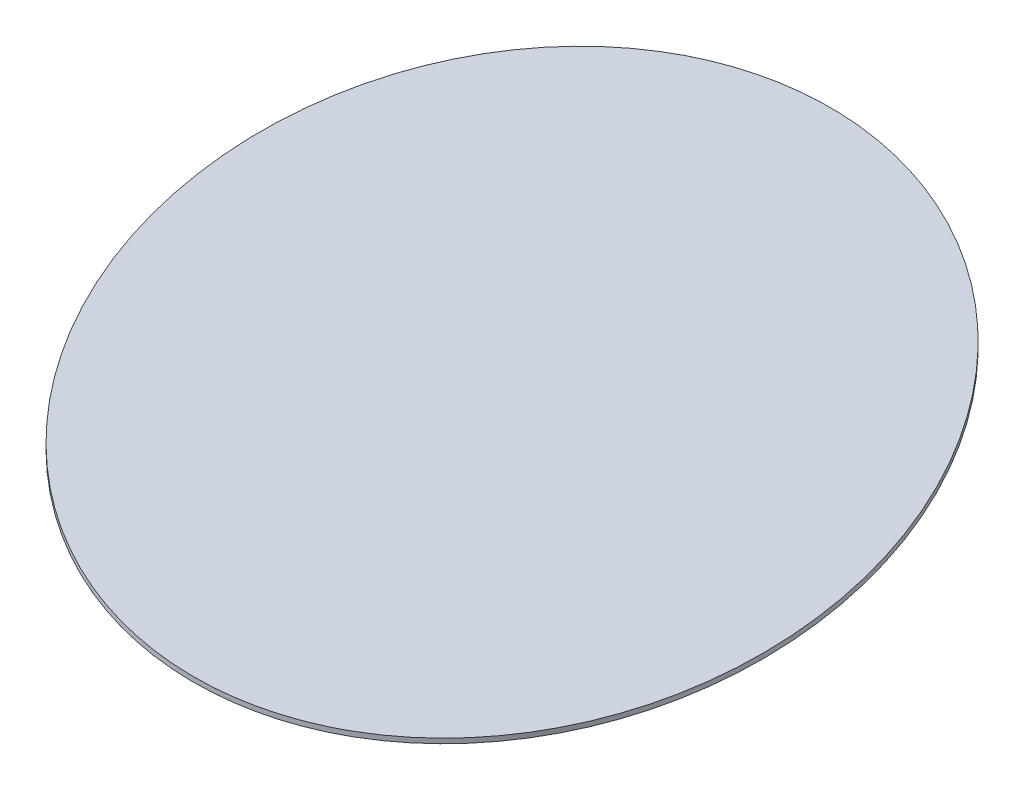
from build123d import *

# Parameters (mm, degrees)
SKETCH1_RX          = 355
SKETCH1_RY          = 265
BOSS_EXTRUDE1_DEPTH = 4


with BuildPart() as part:
    # Sketch1 → Boss-Extrude1 (new body)
    with BuildSketch(Plane(origin=(0, 0, 0), x_dir=(1, 0, 0), z_dir=(0, 1, 0))):
        with Locations(Location((0, 0), (0, 0, -60))):
            Ellipse(SKETCH1_RX, SKETCH1_RY)
    extrude(amount=BOSS_EXTRUDE1_DEPTH)


solid = part.part
